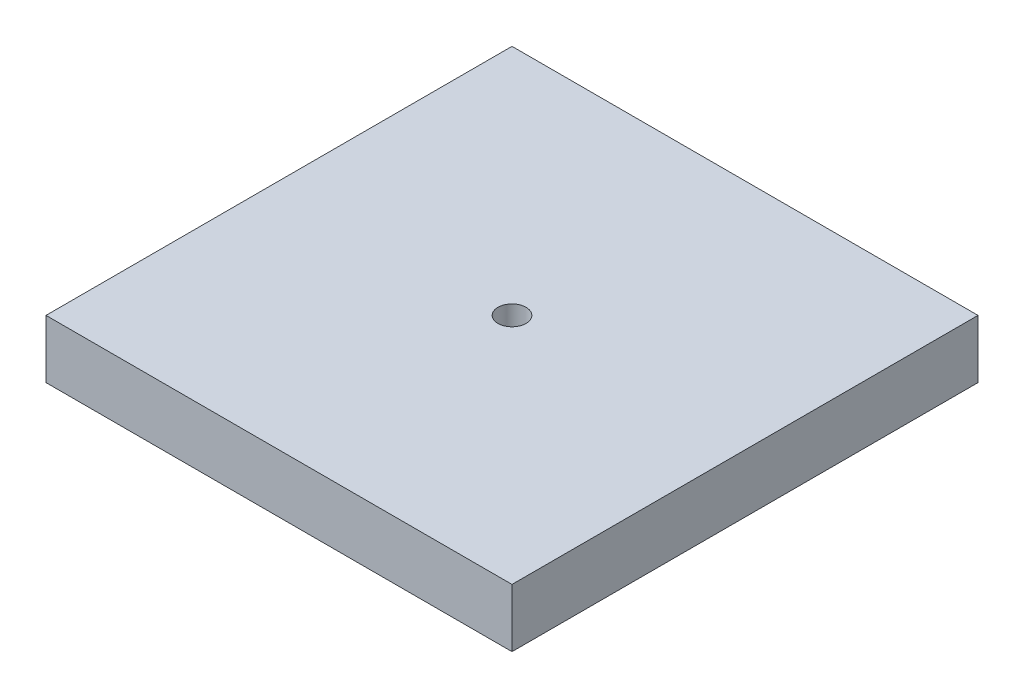
from build123d import *

# Parameters (mm, degrees)
SKETCH1_W           = 40
SKETCH1_H           = 40
SKETCH1_R           = 1.205
BOSS_EXTRUDE1_DEPTH = 5


with BuildPart() as part:
    # Sketch1 → Boss-Extrude1 (new body)
    with BuildSketch(Plane(origin=(0, 0, 0), x_dir=(1, 0, 0), z_dir=(0, 1, 0))):
        Rectangle(SKETCH1_W, SKETCH1_H)
        Circle(SKETCH1_R, mode=Mode.SUBTRACT)
    extrude(amount=BOSS_EXTRUDE1_DEPTH)


solid = part.part
